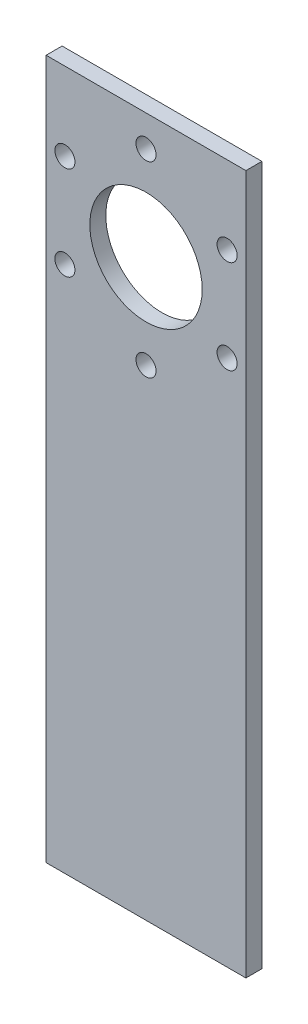
from build123d import *

# Parameters (mm, degrees)
SKETCH2_W              = 50.8
SKETCH2_H              = 177.8
SKETCH2_R              = 14.2875
BOSS_EXTRUDE1_DEPTH    = 4.064
F_10_CLEARANCE_HOLE1_D = 5.1054


with BuildPart() as part:
    # Sketch2 → Boss-Extrude1 (new body)
    with BuildSketch(Plane.XY):
        with Locations((25.4, 88.9)):
            Rectangle(SKETCH2_W, SKETCH2_H)
        with Locations((25.4, 146.05)):
            Circle(SKETCH2_R, mode=Mode.SUBTRACT)
    extrude(amount=BOSS_EXTRUDE1_DEPTH)

    # #10 Clearance Hole1 (through all)
    with Locations(Plane.XY.offset(4.064)):
        with Locations((46.022229928, 157.95625), (25.4, 169.8625), (4.777770072, 157.95625), (4.777770072, 134.14375), (25.4, 122.2375), (46.022229928, 134.14375)):
            Hole(F_10_CLEARANCE_HOLE1_D / 2)


solid = part.part
